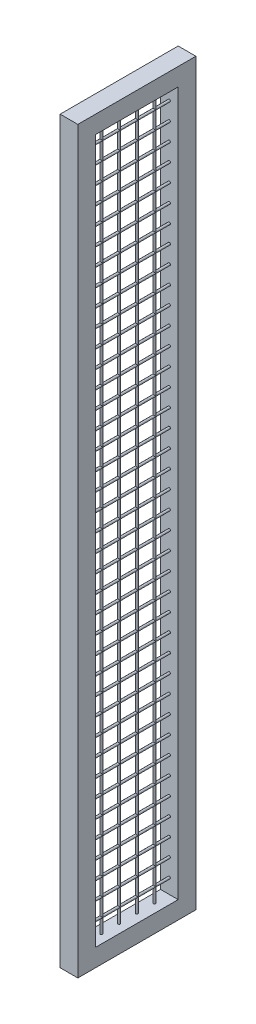
from build123d import *

# Parameters (mm, degrees)
SCHIZZO1_R                      = 3.75
ESTRUSIONE_ESTRUSIONE1_DEPTH    = 400
ESTRUSIONE_ESTRUSIONE1_2_DEPTH  = 400
ESTRUSIONE_ESTRUSIONE1_3_DEPTH  = 400
ESTRUSIONE_ESTRUSIONE1_4_DEPTH  = 400
ESTRUSIONE_ESTRUSIONE1_5_DEPTH  = 400
ESTRUSIONE_ESTRUSIONE1_6_DEPTH  = 400
ESTRUSIONE_ESTRUSIONE1_7_DEPTH  = 400
ESTRUSIONE_ESTRUSIONE1_8_DEPTH  = 400
ESTRUSIONE_ESTRUSIONE1_9_DEPTH  = 400
ESTRUSIONE_ESTRUSIONE1_10_DEPTH = 400
ESTRUSIONE_ESTRUSIONE1_11_DEPTH = 400
ESTRUSIONE_ESTRUSIONE1_12_DEPTH = 400
ESTRUSIONE_ESTRUSIONE1_13_DEPTH = 400
ESTRUSIONE_ESTRUSIONE1_14_DEPTH = 400
ESTRUSIONE_ESTRUSIONE1_15_DEPTH = 400
ESTRUSIONE_ESTRUSIONE1_16_DEPTH = 400
ESTRUSIONE_ESTRUSIONE1_17_DEPTH = 400
ESTRUSIONE_ESTRUSIONE1_18_DEPTH = 400
ESTRUSIONE_ESTRUSIONE1_19_DEPTH = 400
ESTRUSIONE_ESTRUSIONE1_20_DEPTH = 400
ESTRUSIONE_ESTRUSIONE1_21_DEPTH = 400
ESTRUSIONE_ESTRUSIONE1_22_DEPTH = 400
ESTRUSIONE_ESTRUSIONE1_23_DEPTH = 400
ESTRUSIONE_ESTRUSIONE1_24_DEPTH = 400
ESTRUSIONE_ESTRUSIONE1_25_DEPTH = 400
ESTRUSIONE_ESTRUSIONE1_26_DEPTH = 400
ESTRUSIONE_ESTRUSIONE1_27_DEPTH = 400
ESTRUSIONE_ESTRUSIONE1_28_DEPTH = 400
ESTRUSIONE_ESTRUSIONE1_29_DEPTH = 400
ESTRUSIONE_ESTRUSIONE1_30_DEPTH = 400
ESTRUSIONE_ESTRUSIONE1_31_DEPTH = 400
ESTRUSIONE_ESTRUSIONE1_32_DEPTH = 400
ESTRUSIONE_ESTRUSIONE1_33_DEPTH = 400
ESTRUSIONE_ESTRUSIONE1_34_DEPTH = 400
ESTRUSIONE_ESTRUSIONE1_35_DEPTH = 400
ESTRUSIONE_ESTRUSIONE1_36_DEPTH = 400
ESTRUSIONE_ESTRUSIONE1_37_DEPTH = 400
ESTRUSIONE_ESTRUSIONE1_38_DEPTH = 400
ESTRUSIONE_ESTRUSIONE1_39_DEPTH = 400
SCHIZZO1_W                      = 60
SCHIZZO1_H                      = 60
ESTRUSIONE_ESTRUSIONE1_40_DEPTH = 400
ESTRUSIONE_ESTRUSIONE1_41_DEPTH = 400
SCHIZZO2_R                      = 3.75
SCHIZZO2_W                      = 60
SCHIZZO2_H                      = 60
ESTRUSIONE_ESTRUSIONE2_DEPTH    = 2445


with BuildPart() as part:
    # Schizzo1 → Estrusione-Estrusione1 (new body)
    with BuildSketch(Plane.XY):
        with Locations((0, 160)):
            Circle(SCHIZZO1_R)
    extrude(amount=ESTRUSIONE_ESTRUSIONE1_DEPTH)



with BuildPart() as body_2:
    # Schizzo1 → Estrusione-Estrusione1 2 (new body)
    with BuildSketch(Plane.XY):
        with Locations((0, 220)):
            Circle(SCHIZZO1_R)
    extrude(amount=ESTRUSIONE_ESTRUSIONE1_2_DEPTH)


with BuildPart() as body_3:
    # Schizzo1 → Estrusione-Estrusione1 3 (new body)
    with BuildSketch(Plane.XY):
        with Locations((0, 280)):
            Circle(SCHIZZO1_R)
    extrude(amount=ESTRUSIONE_ESTRUSIONE1_3_DEPTH)


with BuildPart() as body_4:
    # Schizzo1 → Estrusione-Estrusione1 4 (new body)
    with BuildSketch(Plane.XY):
        with Locations((0, 340)):
            Circle(SCHIZZO1_R)
    extrude(amount=ESTRUSIONE_ESTRUSIONE1_4_DEPTH)


with BuildPart() as body_5:
    # Schizzo1 → Estrusione-Estrusione1 5 (new body)
    with BuildSketch(Plane.XY):
        with Locations((0, 400)):
            Circle(SCHIZZO1_R)
    extrude(amount=ESTRUSIONE_ESTRUSIONE1_5_DEPTH)


with BuildPart() as body_6:
    # Schizzo1 → Estrusione-Estrusione1 6 (new body)
    with BuildSketch(Plane.XY):
        with Locations((0, 460)):
            Circle(SCHIZZO1_R)
    extrude(amount=ESTRUSIONE_ESTRUSIONE1_6_DEPTH)


with BuildPart() as body_7:
    # Schizzo1 → Estrusione-Estrusione1 7 (new body)
    with BuildSketch(Plane.XY):
        with Locations((0, 520)):
            Circle(SCHIZZO1_R)
    extrude(amount=ESTRUSIONE_ESTRUSIONE1_7_DEPTH)


with BuildPart() as body_8:
    # Schizzo1 → Estrusione-Estrusione1 8 (new body)
    with BuildSketch(Plane.XY):
        with Locations((0, 580)):
            Circle(SCHIZZO1_R)
    extrude(amount=ESTRUSIONE_ESTRUSIONE1_8_DEPTH)


with BuildPart() as body_9:
    # Schizzo1 → Estrusione-Estrusione1 9 (new body)
    with BuildSketch(Plane.XY):
        with Locations((0, 640)):
            Circle(SCHIZZO1_R)
    extrude(amount=ESTRUSIONE_ESTRUSIONE1_9_DEPTH)


with BuildPart() as body_10:
    # Schizzo1 → Estrusione-Estrusione1 10 (new body)
    with BuildSketch(Plane.XY):
        with Locations((0, 700)):
            Circle(SCHIZZO1_R)
    extrude(amount=ESTRUSIONE_ESTRUSIONE1_10_DEPTH)


with BuildPart() as body_11:
    # Schizzo1 → Estrusione-Estrusione1 11 (new body)
    with BuildSketch(Plane.XY):
        with Locations((0, 760)):
            Circle(SCHIZZO1_R)
    extrude(amount=ESTRUSIONE_ESTRUSIONE1_11_DEPTH)


with BuildPart() as body_12:
    # Schizzo1 → Estrusione-Estrusione1 12 (new body)
    with BuildSketch(Plane.XY):
        with Locations((0, 820)):
            Circle(SCHIZZO1_R)
    extrude(amount=ESTRUSIONE_ESTRUSIONE1_12_DEPTH)


with BuildPart() as body_13:
    # Schizzo1 → Estrusione-Estrusione1 13 (new body)
    with BuildSketch(Plane.XY):
        with Locations((0, 880)):
            Circle(SCHIZZO1_R)
    extrude(amount=ESTRUSIONE_ESTRUSIONE1_13_DEPTH)


with BuildPart() as body_14:
    # Schizzo1 → Estrusione-Estrusione1 14 (new body)
    with BuildSketch(Plane.XY):
        with Locations((0, 940)):
            Circle(SCHIZZO1_R)
    extrude(amount=ESTRUSIONE_ESTRUSIONE1_14_DEPTH)


with BuildPart() as body_15:
    # Schizzo1 → Estrusione-Estrusione1 15 (new body)
    with BuildSketch(Plane.XY):
        with Locations((0, 1000)):
            Circle(SCHIZZO1_R)
    extrude(amount=ESTRUSIONE_ESTRUSIONE1_15_DEPTH)


with BuildPart() as body_16:
    # Schizzo1 → Estrusione-Estrusione1 16 (new body)
    with BuildSketch(Plane.XY):
        with Locations((0, 1060)):
            Circle(SCHIZZO1_R)
    extrude(amount=ESTRUSIONE_ESTRUSIONE1_16_DEPTH)


with BuildPart() as body_17:
    # Schizzo1 → Estrusione-Estrusione1 17 (new body)
    with BuildSketch(Plane.XY):
        with Locations((0, 1120)):
            Circle(SCHIZZO1_R)
    extrude(amount=ESTRUSIONE_ESTRUSIONE1_17_DEPTH)


with BuildPart() as body_18:
    # Schizzo1 → Estrusione-Estrusione1 18 (new body)
    with BuildSketch(Plane.XY):
        with Locations((0, 1180)):
            Circle(SCHIZZO1_R)
    extrude(amount=ESTRUSIONE_ESTRUSIONE1_18_DEPTH)


with BuildPart() as body_19:
    # Schizzo1 → Estrusione-Estrusione1 19 (new body)
    with BuildSketch(Plane.XY):
        with Locations((0, 1240)):
            Circle(SCHIZZO1_R)
    extrude(amount=ESTRUSIONE_ESTRUSIONE1_19_DEPTH)


with BuildPart() as body_20:
    # Schizzo1 → Estrusione-Estrusione1 20 (new body)
    with BuildSketch(Plane.XY):
        with Locations((0, 1300)):
            Circle(SCHIZZO1_R)
    extrude(amount=ESTRUSIONE_ESTRUSIONE1_20_DEPTH)


with BuildPart() as body_21:
    # Schizzo1 → Estrusione-Estrusione1 21 (new body)
    with BuildSketch(Plane.XY):
        with Locations((0, 1360)):
            Circle(SCHIZZO1_R)
    extrude(amount=ESTRUSIONE_ESTRUSIONE1_21_DEPTH)


with BuildPart() as body_22:
    # Schizzo1 → Estrusione-Estrusione1 22 (new body)
    with BuildSketch(Plane.XY):
        with Locations((0, 1420)):
            Circle(SCHIZZO1_R)
    extrude(amount=ESTRUSIONE_ESTRUSIONE1_22_DEPTH)


with BuildPart() as body_23:
    # Schizzo1 → Estrusione-Estrusione1 23 (new body)
    with BuildSketch(Plane.XY):
        with Locations((0, 1480)):
            Circle(SCHIZZO1_R)
    extrude(amount=ESTRUSIONE_ESTRUSIONE1_23_DEPTH)


with BuildPart() as body_24:
    # Schizzo1 → Estrusione-Estrusione1 24 (new body)
    with BuildSketch(Plane.XY):
        with Locations((0, 1540)):
            Circle(SCHIZZO1_R)
    extrude(amount=ESTRUSIONE_ESTRUSIONE1_24_DEPTH)


with BuildPart() as body_25:
    # Schizzo1 → Estrusione-Estrusione1 25 (new body)
    with BuildSketch(Plane.XY):
        with Locations((0, 1600)):
            Circle(SCHIZZO1_R)
    extrude(amount=ESTRUSIONE_ESTRUSIONE1_25_DEPTH)


with BuildPart() as body_26:
    # Schizzo1 → Estrusione-Estrusione1 26 (new body)
    with BuildSketch(Plane.XY):
        with Locations((0, 1660)):
            Circle(SCHIZZO1_R)
    extrude(amount=ESTRUSIONE_ESTRUSIONE1_26_DEPTH)


with BuildPart() as body_27:
    # Schizzo1 → Estrusione-Estrusione1 27 (new body)
    with BuildSketch(Plane.XY):
        with Locations((0, 1720)):
            Circle(SCHIZZO1_R)
    extrude(amount=ESTRUSIONE_ESTRUSIONE1_27_DEPTH)


with BuildPart() as body_28:
    # Schizzo1 → Estrusione-Estrusione1 28 (new body)
    with BuildSketch(Plane.XY):
        with Locations((0, 1780)):
            Circle(SCHIZZO1_R)
    extrude(amount=ESTRUSIONE_ESTRUSIONE1_28_DEPTH)


with BuildPart() as body_29:
    # Schizzo1 → Estrusione-Estrusione1 29 (new body)
    with BuildSketch(Plane.XY):
        with Locations((0, 1840)):
            Circle(SCHIZZO1_R)
    extrude(amount=ESTRUSIONE_ESTRUSIONE1_29_DEPTH)


with BuildPart() as body_30:
    # Schizzo1 → Estrusione-Estrusione1 30 (new body)
    with BuildSketch(Plane.XY):
        with Locations((0, 1900)):
            Circle(SCHIZZO1_R)
    extrude(amount=ESTRUSIONE_ESTRUSIONE1_30_DEPTH)


with BuildPart() as body_31:
    # Schizzo1 → Estrusione-Estrusione1 31 (new body)
    with BuildSketch(Plane.XY):
        with Locations((0, 1960)):
            Circle(SCHIZZO1_R)
    extrude(amount=ESTRUSIONE_ESTRUSIONE1_31_DEPTH)


with BuildPart() as body_32:
    # Schizzo1 → Estrusione-Estrusione1 32 (new body)
    with BuildSketch(Plane.XY):
        with Locations((0, 2020)):
            Circle(SCHIZZO1_R)
    extrude(amount=ESTRUSIONE_ESTRUSIONE1_32_DEPTH)


with BuildPart() as body_33:
    # Schizzo1 → Estrusione-Estrusione1 33 (new body)
    with BuildSketch(Plane.XY):
        with Locations((0, 2080)):
            Circle(SCHIZZO1_R)
    extrude(amount=ESTRUSIONE_ESTRUSIONE1_33_DEPTH)


with BuildPart() as body_34:
    # Schizzo1 → Estrusione-Estrusione1 34 (new body)
    with BuildSketch(Plane.XY):
        with Locations((0, 2140)):
            Circle(SCHIZZO1_R)
    extrude(amount=ESTRUSIONE_ESTRUSIONE1_34_DEPTH)


with BuildPart() as body_35:
    # Schizzo1 → Estrusione-Estrusione1 35 (new body)
    with BuildSketch(Plane.XY):
        with Locations((0, 2200)):
            Circle(SCHIZZO1_R)
    extrude(amount=ESTRUSIONE_ESTRUSIONE1_35_DEPTH)


with BuildPart() as body_36:
    # Schizzo1 → Estrusione-Estrusione1 36 (new body)
    with BuildSketch(Plane.XY):
        with Locations((0, 2260)):
            Circle(SCHIZZO1_R)
    extrude(amount=ESTRUSIONE_ESTRUSIONE1_36_DEPTH)


with BuildPart() as body_37:
    # Schizzo1 → Estrusione-Estrusione1 37 (new body)
    with BuildSketch(Plane.XY):
        with Locations((0, 2320)):
            Circle(SCHIZZO1_R)
    extrude(amount=ESTRUSIONE_ESTRUSIONE1_37_DEPTH)


with BuildPart() as body_38:
    # Schizzo1 → Estrusione-Estrusione1 38 (new body)
    with BuildSketch(Plane.XY):
        with Locations((0, 2380)):
            Circle(SCHIZZO1_R)
    extrude(amount=ESTRUSIONE_ESTRUSIONE1_38_DEPTH)


with BuildPart() as body_39:
    # Schizzo1 → Estrusione-Estrusione1 39 (new body)
    with BuildSketch(Plane.XY):
        with Locations((0, 2440)):
            Circle(SCHIZZO1_R)
    extrude(amount=ESTRUSIONE_ESTRUSIONE1_39_DEPTH)


with BuildPart() as body_40:
    # Schizzo1 → Estrusione-Estrusione1 40 (new body)
    with BuildSketch(Plane.XY):
        with Locations((0, 80)):
            Rectangle(SCHIZZO1_W, SCHIZZO1_H)
    extrude(amount=ESTRUSIONE_ESTRUSIONE1_40_DEPTH)


with BuildPart() as body_41:
    # Schizzo1 → Estrusione-Estrusione1 41 (new body)
    with BuildSketch(Plane.XY):
        with Locations((0, 2525)):
            Rectangle(SCHIZZO1_W, SCHIZZO1_H)
    extrude(amount=ESTRUSIONE_ESTRUSIONE1_41_DEPTH)


with BuildPart() as part_1:
    add(part.part)

    add(body_2.part)  # Estrusione-Estrusione2 merges body 2

    add(body_3.part)  # Estrusione-Estrusione2 merges body 3

    add(body_4.part)  # Estrusione-Estrusione2 merges body 4

    add(body_5.part)  # Estrusione-Estrusione2 merges body 5

    add(body_6.part)  # Estrusione-Estrusione2 merges body 6

    add(body_7.part)  # Estrusione-Estrusione2 merges body 7

    add(body_8.part)  # Estrusione-Estrusione2 merges body 8

    add(body_9.part)  # Estrusione-Estrusione2 merges body 9

    add(body_10.part)  # Estrusione-Estrusione2 merges body 10

    add(body_11.part)  # Estrusione-Estrusione2 merges body 11

    add(body_12.part)  # Estrusione-Estrusione2 merges body 12

    add(body_13.part)  # Estrusione-Estrusione2 merges body 13

    add(body_14.part)  # Estrusione-Estrusione2 merges body 14

    add(body_15.part)  # Estrusione-Estrusione2 merges body 15

    add(body_16.part)  # Estrusione-Estrusione2 merges body 16

    add(body_17.part)  # Estrusione-Estrusione2 merges body 17

    add(body_18.part)  # Estrusione-Estrusione2 merges body 18

    add(body_19.part)  # Estrusione-Estrusione2 merges body 19

    add(body_20.part)  # Estrusione-Estrusione2 merges body 20

    add(body_21.part)  # Estrusione-Estrusione2 merges body 21

    add(body_22.part)  # Estrusione-Estrusione2 merges body 22

    add(body_23.part)  # Estrusione-Estrusione2 merges body 23

    add(body_24.part)  # Estrusione-Estrusione2 merges body 24

    add(body_25.part)  # Estrusione-Estrusione2 merges body 25

    add(body_26.part)  # Estrusione-Estrusione2 merges body 26

    add(body_27.part)  # Estrusione-Estrusione2 merges body 27

    add(body_28.part)  # Estrusione-Estrusione2 merges body 28

    add(body_29.part)  # Estrusione-Estrusione2 merges body 29

    add(body_30.part)  # Estrusione-Estrusione2 merges body 30

    add(body_31.part)  # Estrusione-Estrusione2 merges body 31

    add(body_32.part)  # Estrusione-Estrusione2 merges body 32

    add(body_33.part)  # Estrusione-Estrusione2 merges body 33

    add(body_34.part)  # Estrusione-Estrusione2 merges body 34

    add(body_35.part)  # Estrusione-Estrusione2 merges body 35

    add(body_36.part)  # Estrusione-Estrusione2 merges body 36

    add(body_37.part)  # Estrusione-Estrusione2 merges body 37

    add(body_38.part)  # Estrusione-Estrusione2 merges body 38

    add(body_39.part)  # Estrusione-Estrusione2 merges body 39

    add(body_40.part)  # Estrusione-Estrusione2 merges body 40

    add(body_41.part)  # Estrusione-Estrusione2 merges body 41
    # Schizzo2 → Estrusione-Estrusione2 (add)
    with BuildSketch(Plane(origin=(0, 2555, 0), x_dir=(1, 0, 0), z_dir=(0, 1, 0))):
        with Locations((0, -110)):
            Circle(SCHIZZO2_R)
        with Locations((0, -170)):
            Circle(SCHIZZO2_R)
        with Locations((0, -230)):
            Circle(SCHIZZO2_R)
        with Locations((0, -290)):
            Circle(SCHIZZO2_R)
        with Locations((0, -30)):
            Rectangle(SCHIZZO2_W, SCHIZZO2_H)
        with Locations((0, -370)):
            Rectangle(SCHIZZO2_W, SCHIZZO2_H)
    extrude(amount=-ESTRUSIONE_ESTRUSIONE2_DEPTH)


solid = part_1.part
